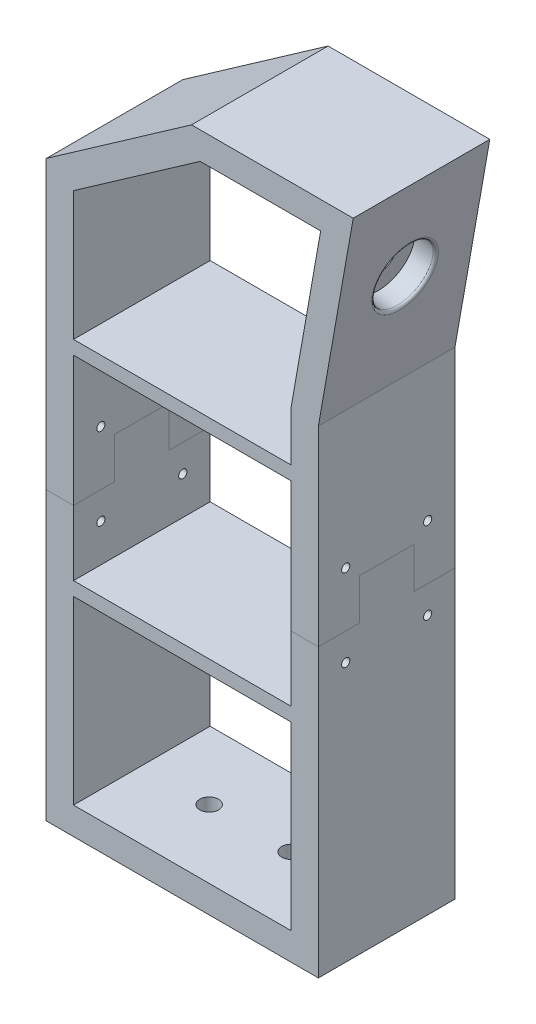
from build123d import *

# Parameters (mm, degrees)
BOSS_EXTRUDE1_DEPTH    = 50
SKETCH10_R             = 3.425
CUT_EXTRUDE5_DEPTH     = 10
SKETCH11_W             = 79.637459777
SKETCH11_H             = 5
BOSS_EXTRUDE3_DEPTH    = 50
SKETCH14_R             = 11.025
CUT_EXTRUDE6_DEPTH     = 8
SKETCH15_R             = 4.05
CUT_EXTRUDE7_DEPTH     = 3
FILLET1_R              = 1
SKETCH16_R             = 1.5
CUT_EXTRUDE8_DEPTH     = 277.151028537
SPLIT1_SURFACE_1_BACK  = 277.151
SPLIT1_SURFACE_1_DEPTH = 554.302
SPLIT1_SURFACE_2_BACK  = 277.151
SPLIT1_SURFACE_2_DEPTH = 554.302


with BuildPart() as part:
    # Sketch2 → Boss-Extrude1 (new body)
    with BuildSketch(Plane.XY):
        Polygon((-40.506485759, 0), (59.130974018, 0), (59.130974018, 175), (71.870010435, 247.246665631), (12.687265519, 247.246665631), (-40.506485759, 210), align=None)
        Polygon((49.130974018, 175.874886635), (59.952474509, 237.246665631), (15.840253408, 237.246665631), (-30.506485759, 204.794329494), (-30.506485759, 10), (49.130974018, 10), align=None, mode=Mode.SUBTRACT)
    extrude(amount=BOSS_EXTRUDE1_DEPTH)

    # Sketch10 → Cut-Extrude5 (cut)
    with BuildSketch(Plane(origin=(0, 10, 0), x_dir=(1, 0, 0), z_dir=(0, 1, 0))):
        with Locations(Location((-5.851287133, -25, 0), (0, 0, 270))):
            Circle(SKETCH10_R)
        with Locations(Location((24.130974018, -25, 0), (0, 0, 270))):
            Circle(SKETCH10_R)
    extrude(amount=-CUT_EXTRUDE5_DEPTH, mode=Mode.SUBTRACT)

    # Sketch11 → Boss-Extrude3 (add)
    with BuildSketch(Plane.XY.offset(50)):
        with Locations((9.31224413, 155.135730726)):
            Rectangle(SKETCH11_W, SKETCH11_H)
        with Locations((9.31224413, 78.651297101)):
            Rectangle(SKETCH11_W, SKETCH11_H)
    extrude(amount=-BOSS_EXTRUDE3_DEPTH)

    # Sketch14 → Cut-Extrude6 (cut)
    with BuildSketch(Plane(origin=(27.42119444, -4.835096423, 0), x_dir=(0, 0, -1), z_dir=(0.9848077530122082, -0.17364817766693028, 0))):
        with Locations(Location((-25, 221.609342659, 0), (0, 0, 90))):
            Circle(SKETCH14_R)
    extrude(amount=-CUT_EXTRUDE6_DEPTH, mode=Mode.SUBTRACT)

    # Sketch15 → Cut-Extrude7 (cut)
    with BuildSketch(Plane(origin=(19.542732416, -3.445911002, 0), x_dir=(0, 0, -1), z_dir=(0.984807753012208, -0.1736481776669303, 0))):
        with Locations(Location((-25, 221.609342659, 0), (0, 0, 90))):
            Circle(SKETCH15_R)
    extrude(amount=-CUT_EXTRUDE7_DEPTH, mode=Mode.SUBTRACT)

    # Fillet1
    fillet1_edges = [part.edges().sort_by_distance(p)[0] for p in [
        (63.988781788, 202.549996891, 25),
    ]]
    fillet(fillet1_edges, radius=FILLET1_R)

    # Sketch16 → Cut-Extrude8 (cut, through all)
    with BuildSketch(Plane.ZY.offset(40.506485759)):
        with Locations(Location((40, 125, 0), (0, 0, 270))):
            Circle(SKETCH16_R)
        with Locations(Location((40, 95, 0), (0, 0, 270))):
            Circle(SKETCH16_R)
        with Locations(Location((10, 95, 0), (0, 0, 270))):
            Circle(SKETCH16_R)
        with Locations(Location((10, 125, 0), (0, 0, 270))):
            Circle(SKETCH16_R)
    extrude(amount=-CUT_EXTRUDE8_DEPTH, mode=Mode.SUBTRACT)


with BuildPart() as body_2:
    # Split1: the piece behind the surface
    add(part.part)
    # Split1 surface: a surface, the sketch's curves swept straight by 554.302 mm
    with BuildLine(Plane.ZY.offset(40.506485759).offset(-SPLIT1_SURFACE_1_BACK), mode=Mode.PRIVATE) as split1_surface_1_path:
        Line((0, 105), (15, 105))
        Line((15, 105), (15, 120))
        Line((15, 120), (35, 120))
        Line((35, 120), (35, 105))
        Line((35, 105), (50, 105))
    split1_surface_1 = Shell.extrude(split1_surface_1_path.wire(), (-1 * SPLIT1_SURFACE_1_DEPTH, 0 * SPLIT1_SURFACE_1_DEPTH, 0 * SPLIT1_SURFACE_1_DEPTH))
    split(bisect_by=split1_surface_1, keep=Keep.BOTTOM)


with BuildPart() as part_1:
    add(part.part)

    # Split1: split by a surface, the side it looks to stays
    # Split1 surface: a surface, the sketch's curves swept straight by 554.302 mm
    with BuildLine(Plane.ZY.offset(40.506485759).offset(-SPLIT1_SURFACE_2_BACK), mode=Mode.PRIVATE) as split1_surface_2_path:
        Line((0, 105), (15, 105))
        Line((15, 105), (15, 120))
        Line((15, 120), (35, 120))
        Line((35, 120), (35, 105))
        Line((35, 105), (50, 105))
    split1_surface_2 = Shell.extrude(split1_surface_2_path.wire(), (-1 * SPLIT1_SURFACE_2_DEPTH, 0 * SPLIT1_SURFACE_2_DEPTH, 0 * SPLIT1_SURFACE_2_DEPTH))
    split(bisect_by=split1_surface_2, keep=Keep.TOP)


solid = Compound([body_2.part, part_1.part])
